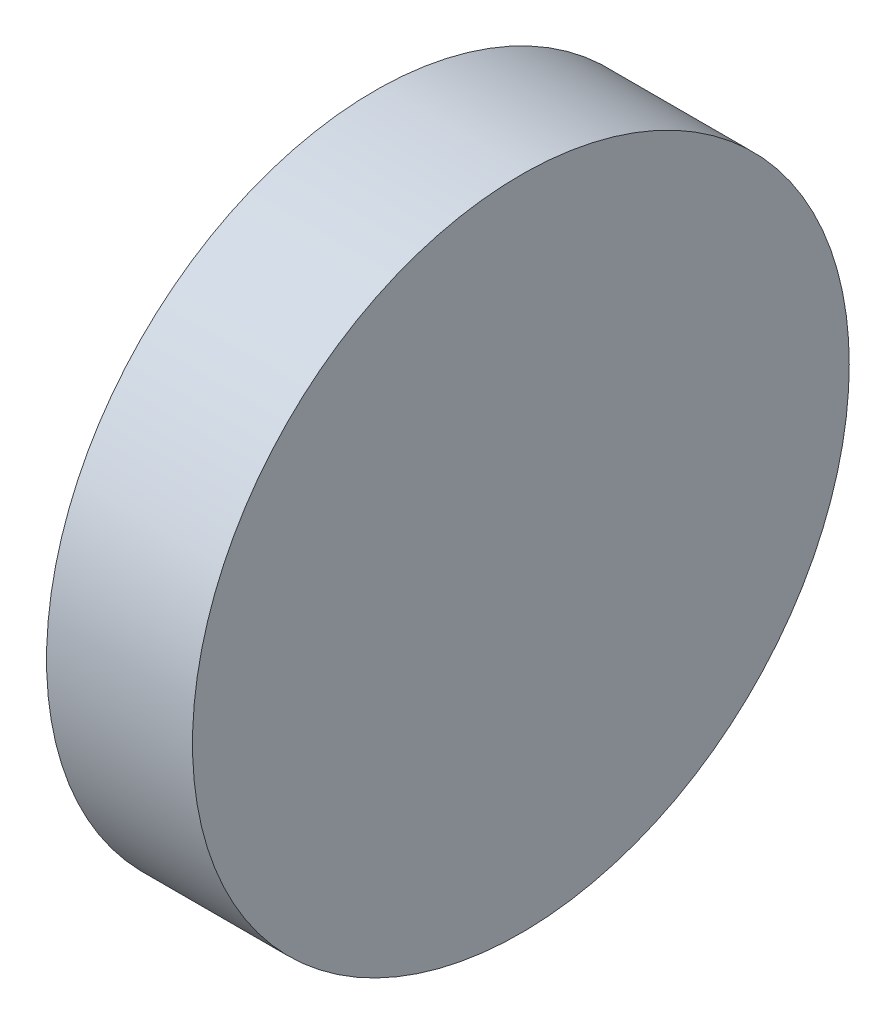
from build123d import *

# Parameters (mm, degrees)
ESQUISSE1_R        = 22.5
BOSS_EXTRU_1_DEPTH = 10


with BuildPart() as part:
    # Esquisse1 → Boss.-Extru.1 (new body)
    with BuildSketch(Plane(origin=(0, 0, 0), x_dir=(0, 0, -1), z_dir=(1, 0, 0))):
        Circle(ESQUISSE1_R)
    extrude(amount=BOSS_EXTRU_1_DEPTH)


solid = part.part
